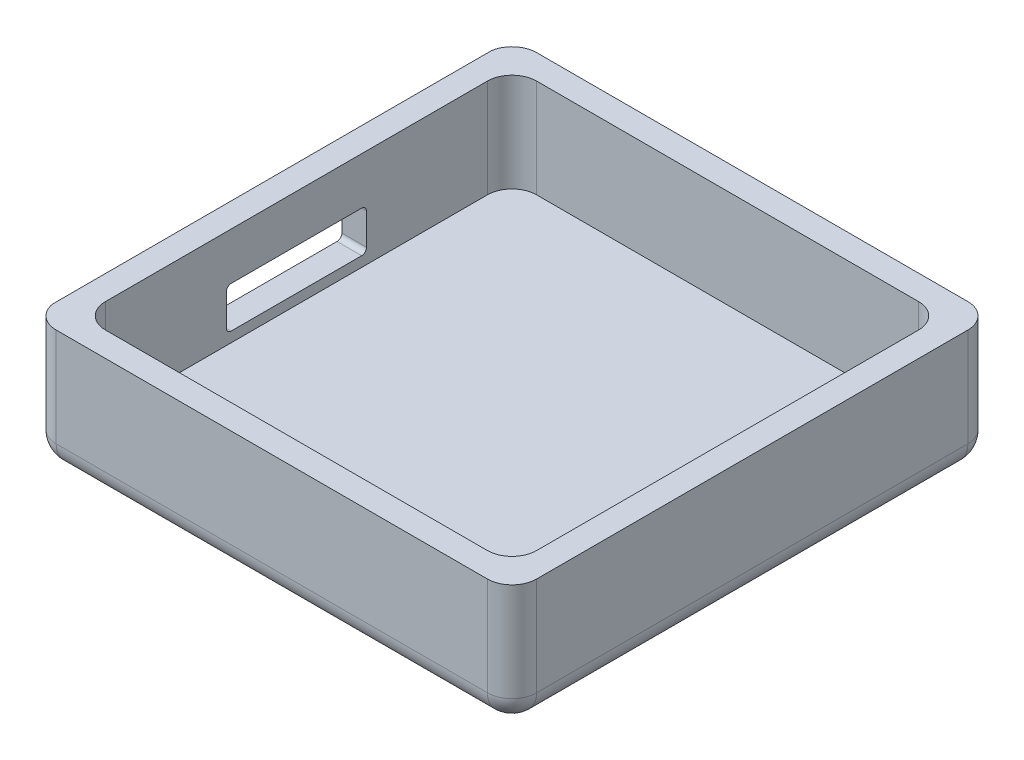
from build123d import *

# Parameters (mm, degrees)
SKETCH1_W                = 5.08
SKETCH1_H                = 5.08
BOSS_EXTRUDE1_DEPTH      = 12.7
SKETCH2_W                = 99.06
SKETCH2_H                = 99.06
BOSS_EXTRUDE2_DEPTH      = 5.08
FILLET1_R                = 5.08
BOSS_EXTRUDE3_DEPTH      = 10.922
BOSS_EXTRUDE3_DEPTH_BACK = 17.78
SKETCH4_R                = 2.032
BOSS_EXTRUDE4_DEPTH      = 12.7
SKETCH7_R                = 1.143
CUT_EXTRUDE4_DEPTH       = 10.922
SKETCH8_R                = 2.032
CUT_EXTRUDE5_DEPTH       = 12.7
SKETCH5_R                = 1.905
SKETCH5_R_2              = 1.693431134
CUT_EXTRUDE6_DEPTH       = 5.08
SKETCH9_R                = 1.905
SKETCH9_R_2              = 1.016
BOSS_EXTRUDE5_DEPTH      = 3.81
SKETCH6_R                = 1.905
CUT_EXTRUDE7_DEPTH       = 5.08
SKETCH10_R               = 1.905
SKETCH10_R_2             = 1.016
SKETCH10_R_3             = 2.032
BOSS_EXTRUDE8_DEPTH      = 3.81
SKETCH11_W               = 88.9
SKETCH11_H               = 88.9
BOSS_EXTRUDE9_DEPTH      = 7.62
FILLET5_R                = 5.08
SKETCH12_W               = 62.122594268
SKETCH12_H               = 12.7
BOSS_EXTRUDE10_DEPTH     = 5.08
BOSS_EXTRUDE11_START     = -5.08
SKETCH13_W               = 40.450281948
SKETCH13_H               = 12.7
BOSS_EXTRUDE11_DEPTH     = 5.08
SKETCH14_W               = 28.9
SKETCH14_H               = 4.25
CUT_EXTRUDE8_DEPTH       = 5.08
FILLET6_R                = 1


with BuildPart() as part:
    # Sketch1 → Boss-Extrude1 (new body)
    with BuildSketch(Plane(origin=(0, 0, 0), x_dir=(1, 0, 0), z_dir=(0, 1, 0))):
        Polygon((-5.08, 0), (0, 0), (0, 88.9), (88.9, 88.9), (88.9, 93.98), (-5.08, 93.98), align=None)
        Polygon((88.9, 0), (0, 0), (0, -5.08), (93.98, -5.08), (93.98, 88.9), (88.9, 88.9), align=None)
        with Locations((-2.54, -2.54)):
            Rectangle(SKETCH1_W, SKETCH1_H)
        with Locations((91.44, 91.44)):
            Rectangle(SKETCH1_W, SKETCH1_H)
    extrude(amount=-BOSS_EXTRUDE1_DEPTH)

    # Sketch2 → Boss-Extrude2 (add)
    with BuildSketch(Plane(origin=(0, -12.7, 0), x_dir=(-1, 0, 0), z_dir=(0, -1, 0))):
        with Locations((-44.45, 44.45)):
            Rectangle(SKETCH2_W, SKETCH2_H)
    extrude(amount=BOSS_EXTRUDE2_DEPTH)

    # Fillet1
    fillet1_edges = [part.edges().sort_by_distance(p)[0] for p in [
        (-5.08, -8.89, 5.08),
        (-5.08, -8.89, -93.98),
        (93.98, -8.89, -93.98),
        (93.98, -8.89, 5.08),
        (-5.08, -17.78, -44.45),
        (44.45, -17.78, -93.98),
        (93.98, -17.78, -44.45),
        (44.45, -17.78, 5.08),
    ]]
    fillet(fillet1_edges, radius=FILLET1_R)

    # Sketch3 → Boss-Extrude3 (add, two sides)
    with BuildSketch(Plane(origin=(0, 0, 0), x_dir=(1, 0, 0), z_dir=(0, 1, 0))) as boss_extrude3_sk:
        with BuildLine():
            ThreePointArc((16.638673661, 17.781673661), (15.582679356, 17.076080824), (15.83045061, 15.83045061))
            Line((15.83045061, 15.83045061), (16.638673661, 16.638673661))
            Line((16.638673661, 16.638673661), (16.638673661, 17.781673661))
        make_face()
        with BuildLine():
            Line((16.638673661, 17.781673661), (16.638673661, 16.638673661))
            Line((16.638673661, 16.638673661), (17.446896712, 17.446896712))
            ThreePointArc((17.446896712, 17.446896712), (17.076080824, 17.694667967), (16.638673661, 17.781673661))
        make_face()
        with BuildLine():
            Line((16.638673661, 16.638673661), (15.83045061, 15.83045061))
            ThreePointArc((15.83045061, 15.83045061), (17.076080824, 15.582679356), (17.781673661, 16.638673661))
            Line((17.781673661, 16.638673661), (16.638673661, 16.638673661))
        make_face()
        with BuildLine():
            Line((17.446896712, 17.446896712), (16.638673661, 16.638673661))
            Line((16.638673661, 16.638673661), (17.781673661, 16.638673661))
            ThreePointArc((17.781673661, 16.638673661), (17.694667967, 17.076080824), (17.446896712, 17.446896712))
        make_face()
        with BuildLine():
            ThreePointArc((71.453103288, 17.446896712), (71.205332033, 17.076080824), (71.118326339, 16.638673661))
            Line((71.118326339, 16.638673661), (72.261326339, 16.638673661))
            Line((72.261326339, 16.638673661), (71.453103288, 17.446896712))
        make_face()
        with BuildLine():
            Line((72.261326339, 16.638673661), (71.118326339, 16.638673661))
            ThreePointArc((71.118326339, 16.638673661), (71.823919176, 15.582679356), (73.06954939, 15.83045061))
            Line((73.06954939, 15.83045061), (72.261326339, 16.638673661))
        make_face()
        with BuildLine():
            Line((72.261326339, 17.781673661), (72.261326339, 16.638673661))
            Line((72.261326339, 16.638673661), (73.06954939, 15.83045061))
            ThreePointArc((73.06954939, 15.83045061), (73.317320644, 16.201266498), (73.404326339, 16.638673661))
            ThreePointArc((73.404326339, 16.638673661), (73.06954939, 17.446896712), (72.261326339, 17.781673661))
        make_face()
        with BuildLine():
            Line((71.453103288, 17.446896712), (72.261326339, 16.638673661))
            Line((72.261326339, 16.638673661), (72.261326339, 17.781673661))
            ThreePointArc((72.261326339, 17.781673661), (71.823919176, 17.694667967), (71.453103288, 17.446896712))
        make_face()
        with BuildLine():
            ThreePointArc((71.118326339, 72.261326339), (71.205332033, 71.823919176), (71.453103288, 71.453103288))
            Line((71.453103288, 71.453103288), (72.261326339, 72.261326339))
            Line((72.261326339, 72.261326339), (71.118326339, 72.261326339))
        make_face()
        with BuildLine():
            Line((71.118326339, 72.261326339), (72.261326339, 72.261326339))
            Line((72.261326339, 72.261326339), (73.06954939, 73.06954939))
            ThreePointArc((73.06954939, 73.06954939), (71.823919176, 73.317320644), (71.118326339, 72.261326339))
        make_face()
        with BuildLine():
            Line((72.261326339, 72.261326339), (71.453103288, 71.453103288))
            ThreePointArc((71.453103288, 71.453103288), (71.823919176, 71.205332033), (72.261326339, 71.118326339))
            Line((72.261326339, 71.118326339), (72.261326339, 72.261326339))
        make_face()
        with BuildLine():
            Line((73.06954939, 73.06954939), (72.261326339, 72.261326339))
            Line((72.261326339, 72.261326339), (72.261326339, 71.118326339))
            ThreePointArc((72.261326339, 71.118326339), (73.06954939, 71.453103288), (73.404326339, 72.261326339))
            ThreePointArc((73.404326339, 72.261326339), (73.317320644, 72.698733502), (73.06954939, 73.06954939))
        make_face()
        with BuildLine():
            ThreePointArc((15.83045061, 73.06954939), (15.582679356, 71.823919176), (16.638673661, 71.118326339))
            Line((16.638673661, 71.118326339), (16.638673661, 72.261326339))
            Line((16.638673661, 72.261326339), (15.83045061, 73.06954939))
        make_face()
        with BuildLine():
            Line((16.638673661, 72.261326339), (16.638673661, 71.118326339))
            ThreePointArc((16.638673661, 71.118326339), (17.076080824, 71.205332033), (17.446896712, 71.453103288))
            Line((17.446896712, 71.453103288), (16.638673661, 72.261326339))
        make_face()
        with BuildLine():
            Line((17.781673661, 72.261326339), (16.638673661, 72.261326339))
            Line((16.638673661, 72.261326339), (17.446896712, 71.453103288))
            ThreePointArc((17.446896712, 71.453103288), (17.694667967, 71.823919176), (17.781673661, 72.261326339))
        make_face()
        with BuildLine():
            Line((15.83045061, 73.06954939), (16.638673661, 72.261326339))
            Line((16.638673661, 72.261326339), (17.781673661, 72.261326339))
            ThreePointArc((17.781673661, 72.261326339), (17.076080824, 73.317320644), (15.83045061, 73.06954939))
        make_face()
    extrude(amount=BOSS_EXTRUDE3_DEPTH)
    extrude(boss_extrude3_sk.sketch, amount=-BOSS_EXTRUDE3_DEPTH_BACK)

    # Sketch4 → Boss-Extrude4 (add)
    with BuildSketch(Plane(origin=(0, 0, 0), x_dir=(1, 0, 0), z_dir=(0, 1, 0))):
        with Locations((72.261326339, 16.638673661)):
            Circle(SKETCH4_R)
        with Locations((16.638673661, 16.638673661)):
            Circle(SKETCH4_R)
        with Locations((72.261326339, 72.261326339)):
            Circle(SKETCH4_R)
        with Locations((16.638673661, 72.261326339)):
            Circle(SKETCH4_R)
    extrude(amount=-BOSS_EXTRUDE4_DEPTH)

    # Sketch7 → Cut-Extrude4 (cut)
    with BuildSketch(Plane(origin=(0, 10.922, 0), x_dir=(1, 0, 0), z_dir=(0, 1, 0))):
        with Locations((72.261326339, 72.261326339)):
            Circle(SKETCH7_R)
        with Locations((16.638673661, 72.261326339)):
            Circle(SKETCH7_R)
        with Locations((72.261326339, 16.638673661)):
            Circle(SKETCH7_R)
        with Locations((16.638673661, 16.638673661)):
            Circle(SKETCH7_R)
    extrude(amount=-CUT_EXTRUDE4_DEPTH, mode=Mode.SUBTRACT)

    # Sketch8 → Cut-Extrude5 (cut)
    with BuildSketch(Plane(origin=(0, 0, 0), x_dir=(1, 0, 0), z_dir=(0, 1, 0))):
        with Locations((72.261326339, 16.638673661)):
            Circle(SKETCH8_R)
        with Locations((72.261326339, 72.261326339)):
            Circle(SKETCH8_R)
        with Locations((16.638673661, 72.261326339)):
            Circle(SKETCH8_R)
        with Locations((16.638673661, 16.638673661)):
            Circle(SKETCH8_R)
    extrude(amount=-CUT_EXTRUDE5_DEPTH, mode=Mode.SUBTRACT)

    # Sketch5 → Cut-Extrude6 (cut)
    with BuildSketch(Plane.XY.offset(5.08)):
        with Locations((30.48, -6.35)):
            Circle(SKETCH5_R)
        with BuildLine():
            ThreePointArc((44.45, -4.445), (43.201840683, -4.910860216), (42.564146215, -6.080592316))
            Line((42.564146215, -6.080592316), (44.45, -6.35))
            Line((44.45, -6.35), (46.335853785, -6.080592316))
            ThreePointArc((46.335853785, -6.080592316), (45.698159317, -4.910860216), (44.45, -4.445))
        make_face()
        with BuildLine():
            Line((44.45, -6.35), (42.564146215, -6.080592316))
            ThreePointArc((42.564146215, -6.080592316), (42.545, -6.35), (42.564146215, -6.619407684))
            Line((42.564146215, -6.619407684), (44.45, -6.35))
        make_face()
        with BuildLine():
            Line((46.335853785, -6.080592316), (44.45, -6.35))
            Line((44.45, -6.35), (46.335853785, -6.619407684))
            ThreePointArc((46.335853785, -6.619407684), (46.350207418, -6.485043583), (46.355, -6.35))
            ThreePointArc((46.355, -6.35), (46.350207418, -6.214956417), (46.335853785, -6.080592316))
        make_face()
        with BuildLine():
            Line((46.335853785, -6.619407684), (44.45, -6.35))
            Line((44.45, -6.35), (42.564146215, -6.619407684))
            ThreePointArc((42.564146215, -6.619407684), (43.201840683, -7.789139784), (44.45, -8.255))
            ThreePointArc((44.45, -8.255), (45.698159317, -7.789139784), (46.335853785, -6.619407684))
        make_face()
        with Locations((58.418397854, -6.561568866)):
            Circle(SKETCH5_R_2)
    extrude(amount=-CUT_EXTRUDE6_DEPTH, mode=Mode.SUBTRACT)

    # Sketch9 → Boss-Extrude5 (add)
    with BuildSketch(Plane(origin=(0, 0, 0), x_dir=(-1, 0, 0), z_dir=(0, 0, -1))):
        with Locations((-58.418397854, -6.561568866)):
            Circle(SKETCH9_R)
        with Locations((-58.418397854, -6.561568866)):
            Circle(SKETCH9_R_2, mode=Mode.SUBTRACT)
        with Locations((-44.45, -6.35)):
            Circle(SKETCH9_R)
        with Locations((-44.45, -6.35)):
            Circle(SKETCH9_R_2, mode=Mode.SUBTRACT)
        with Locations((-30.48, -6.35)):
            Circle(SKETCH9_R)
        with Locations((-30.48, -6.35)):
            Circle(SKETCH9_R_2, mode=Mode.SUBTRACT)
    extrude(amount=-BOSS_EXTRUDE5_DEPTH)

    # Sketch6 → Cut-Extrude7 (cut)
    with BuildSketch(Plane.ZY.offset(5.08)):
        with BuildLine():
            Line((-54.653499975, -4.892357146), (-56.649300025, -4.607242854))
            ThreePointArc((-56.649300025, -4.607242854), (-57.785, -6.35), (-56.649300025, -8.092757146))
            Line((-56.649300025, -8.092757146), (-54.653499975, -7.807642854))
            ThreePointArc((-54.653499975, -7.807642854), (-53.975, -6.35), (-54.653499975, -4.892357146))
        make_face()
        with Locations((-67.31, -6.35)):
            Circle(SKETCH6_R)
        with Locations((-44.45, -6.35)):
            Circle(SKETCH6_R)
        with BuildLine():
            Line((-32.217974947, -4.60256785), (-34.279225053, -4.89703215))
            ThreePointArc((-34.279225053, -4.89703215), (-34.942696883, -6.35), (-34.279225053, -7.80296785))
            Line((-34.279225053, -7.80296785), (-32.217974947, -8.09743215))
            ThreePointArc((-32.217974947, -8.09743215), (-31.097303117, -6.35), (-32.217974947, -4.60256785))
        make_face()
        with Locations((-21.59, -6.35)):
            Circle(SKETCH6_R)
    extrude(amount=-CUT_EXTRUDE7_DEPTH, mode=Mode.SUBTRACT)

    # Sketch10 → Boss-Extrude8 (add)
    with BuildSketch(Plane(origin=(0, 0, 0), x_dir=(0, 0, -1), z_dir=(1, 0, 0))):
        with Locations((21.59, -6.35)):
            Circle(SKETCH10_R)
        with Locations((21.59, -6.35)):
            Circle(SKETCH10_R_2, mode=Mode.SUBTRACT)
        with Locations((33.02, -6.35)):
            Circle(SKETCH10_R_3)
        with Locations((33.02, -6.35)):
            Circle(SKETCH10_R_2, mode=Mode.SUBTRACT)
        with Locations((44.45, -6.35)):
            Circle(SKETCH10_R)
        with Locations((44.45, -6.35)):
            Circle(SKETCH10_R_2, mode=Mode.SUBTRACT)
        with Locations((55.88, -6.35)):
            Circle(SKETCH10_R)
        with Locations((55.88, -6.35)):
            Circle(SKETCH10_R_2, mode=Mode.SUBTRACT)
        with Locations((67.31, -6.35)):
            Circle(SKETCH10_R)
        with Locations((67.31, -6.35)):
            Circle(SKETCH10_R_2, mode=Mode.SUBTRACT)
    extrude(amount=-BOSS_EXTRUDE8_DEPTH)

    # Sketch11 → Boss-Extrude9 (add)
    with BuildSketch(Plane(origin=(0, 0, 0), x_dir=(1, 0, 0), z_dir=(0, 1, 0))):
        with BuildLine():
            ThreePointArc((93.98, 88.9), (92.492102448, 92.492102448), (88.9, 93.98))
            Line((88.9, 93.98), (0, 93.98))
            ThreePointArc((0, 93.98), (-3.29371971, 92.767532866), (-5.015184737, 89.708901759))
            Line((-5.015184737, 89.708901759), (-5.015184737, -0.808901759))
            ThreePointArc((-5.015184737, -0.808901759), (-3.29371971, -3.867532866), (0, -5.08))
            Line((0, -5.08), (88.9, -5.08))
            ThreePointArc((88.9, -5.08), (92.492102448, -3.592102448), (93.98, 0))
            Line((93.98, 0), (93.98, 88.9))
        make_face()
        with Locations((44.45, 44.45)):
            Rectangle(SKETCH11_W, SKETCH11_H, mode=Mode.SUBTRACT)
    extrude(amount=BOSS_EXTRUDE9_DEPTH)

    # Fillet5
    fillet5_edges = [part.edges().sort_by_distance(p)[0] for p in [
        (88.9, -2.54, 0),
        (88.9, -2.54, -88.9),
        (0, -2.54, -88.9),
        (0, -2.54, 0),
    ]]
    fillet(fillet5_edges, radius=FILLET5_R)

    # Sketch12 → Boss-Extrude10 (add)
    with BuildSketch(Plane.ZY.offset(5.08)):
        with Locations((-45.534139922, -6.35)):
            Rectangle(SKETCH12_W, SKETCH12_H)
    extrude(amount=-BOSS_EXTRUDE10_DEPTH)

    # Sketch13 → Boss-Extrude11 (add)
    with BuildSketch(Plane.XY.offset(5.08).offset(BOSS_EXTRUDE11_START)):
        with Locations((45.477393759, -6.35)):
            Rectangle(SKETCH13_W, SKETCH13_H)
    extrude(amount=BOSS_EXTRUDE11_DEPTH)

    # Sketch14 → Cut-Extrude8 (cut)
    with BuildSketch(Plane.ZY.offset(5.08)):
        with Locations((-44.45, -4.225)):
            Rectangle(SKETCH14_W, SKETCH14_H)
        with Locations((-44.45, -8.475)):
            Rectangle(SKETCH14_W, SKETCH14_H)
    extrude(amount=-CUT_EXTRUDE8_DEPTH, mode=Mode.SUBTRACT)

    # Fillet6
    fillet6_edges = [part.edges().sort_by_distance(p)[0] for p in [
        (-2.54, -2.1, -30),
        (-2.54, -10.6, -30),
        (-2.54, -10.6, -58.9),
        (-2.54, -2.1, -58.9),
    ]]
    fillet(fillet6_edges, radius=FILLET6_R)


solid = part.part
